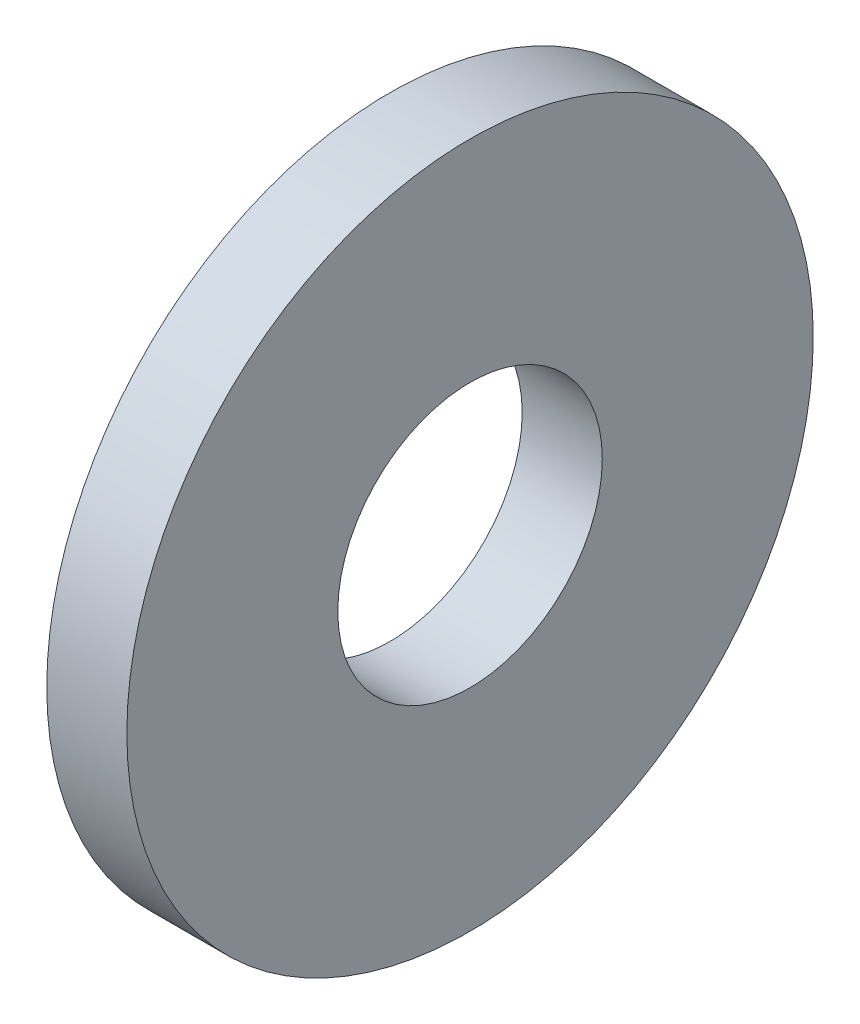
from build123d import *

# Parameters (mm, degrees)
SKETCH1_W = 1.75
SKETCH1_H = 4.61


with BuildPart() as part:
    # Sketch1 → Base-Revolve (revolve)
    with BuildSketch(Plane.XY):
        with Locations((-0.875, 5.195)):
            Rectangle(SKETCH1_W, SKETCH1_H)
    revolve(axis=Axis((-34.925, 0, 0), (1, 0, 0)))


solid = part.part
